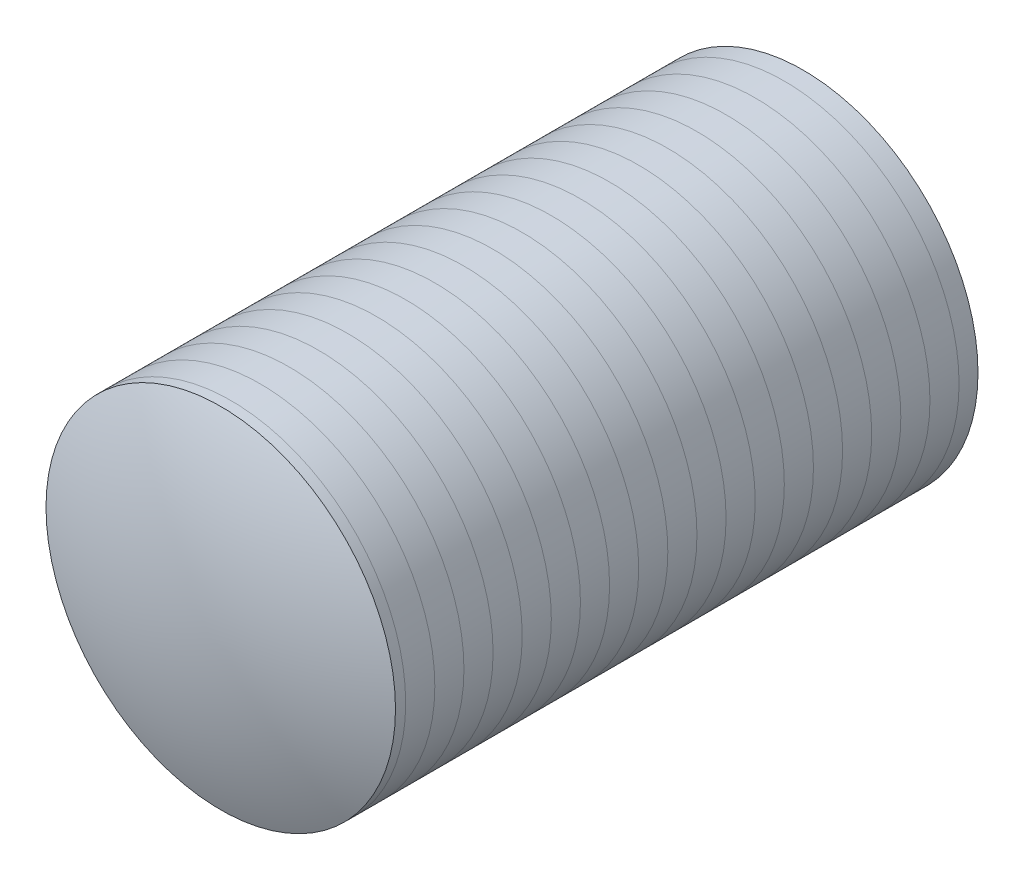
from build123d import *

# Parameters (mm, degrees)
SKETCH2_R           = 6000
BOSS_EXTRUDE1_DEPTH = 20000
DOME1_FACE_RADIUS   = 6000
DOME1_HEIGHT        = 1200


with BuildPart() as part:
    # Sketch2 → Boss-Extrude1 (new body)
    with BuildSketch(Plane.XY):
        Circle(SKETCH2_R)
    extrude(amount=BOSS_EXTRUDE1_DEPTH)

    # Dome1: a dome of height H over a round flat face of radius A is a cap of a sphere of radius (A * A + H * H) / (2 * H)
    dome1_r = (DOME1_FACE_RADIUS * DOME1_FACE_RADIUS + DOME1_HEIGHT * DOME1_HEIGHT) / (2 * DOME1_HEIGHT)
    dome1_base = Plane((0, 0, 20000), z_dir=(0, 0, 1))
    with Locations(dome1_base.offset(DOME1_HEIGHT - dome1_r)):
        dome1_ball = Sphere(dome1_r, mode=Mode.PRIVATE)
    add(split(dome1_ball, bisect_by=dome1_base, keep=Keep.TOP, mode=Mode.PRIVATE))


solid = part.part
